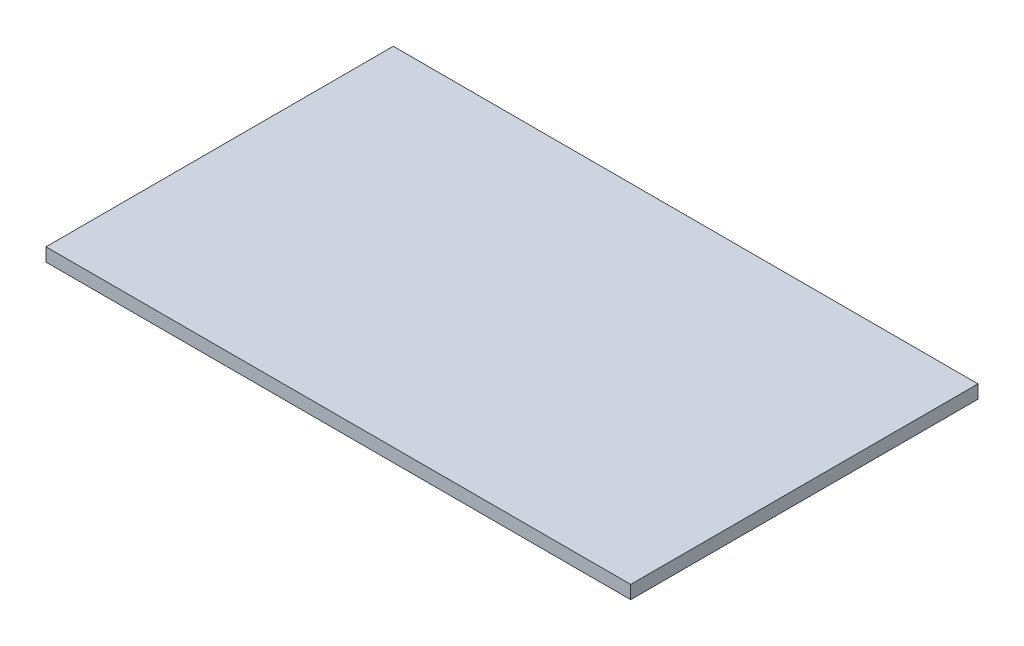
from build123d import *

# Parameters (mm, degrees)
SKETCH1_W           = 1676.4
SKETCH1_H           = 995.68
BOSS_EXTRUDE1_DEPTH = 38.1


with BuildPart() as part:
    # Sketch1 → Boss-Extrude1 (new body)
    with BuildSketch(Plane(origin=(0, 0, 0), x_dir=(1, 0, 0), z_dir=(0, 1, 0))):
        with Locations((838.2, 497.84)):
            Rectangle(SKETCH1_W, SKETCH1_H)
    extrude(amount=BOSS_EXTRUDE1_DEPTH)


solid = part.part
